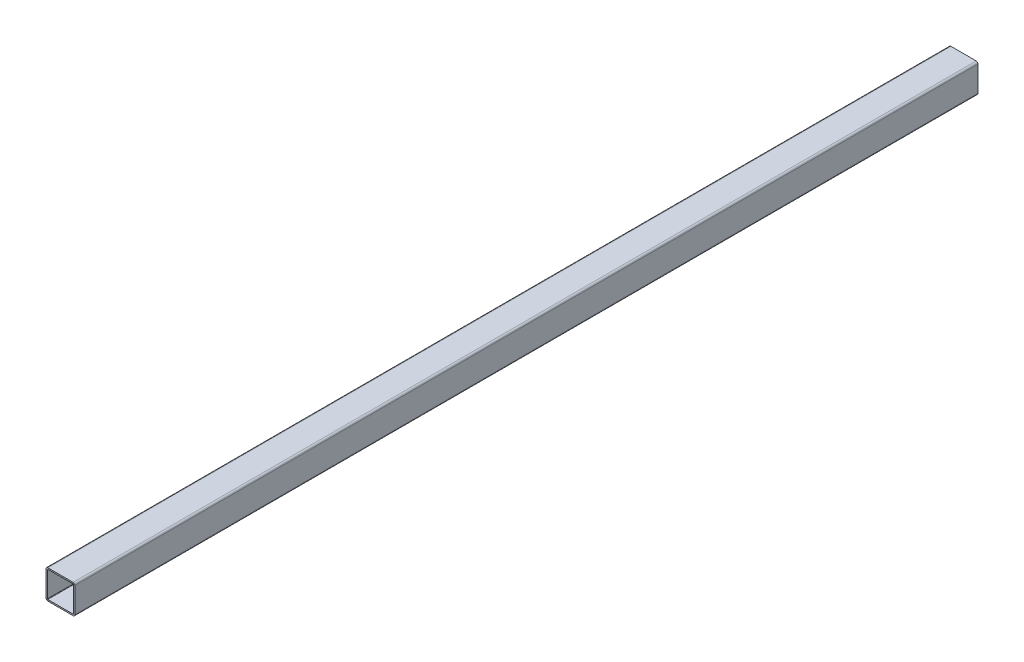
from build123d import *

# Parameters (mm, degrees)
BOSS_EXTRUDE1_DEPTH      = 500
BOSS_EXTRUDE1_DEPTH_BACK = 500


with BuildPart() as part:
    # Sketch1 → Boss-Extrude1 (new body, two sides)
    with BuildSketch(Plane.XY) as boss_extrude1_sk:
        with BuildLine():
            Line((-14, -16), (14, -16))
            ThreePointArc((14, -16), (15.414213562, -15.414213562), (16, -14))
            Line((16, -14), (16, 14))
            ThreePointArc((16, 14), (15.414213562, 15.414213562), (14, 16))
            Line((14, 16), (-14, 16))
            ThreePointArc((-14, 16), (-15.414213562, 15.414213562), (-16, 14))
            Line((-16, 14), (-16, -14))
            ThreePointArc((-16, -14), (-15.414213562, -15.414213562), (-14, -16))
        make_face()
        with BuildLine():
            Line((-14, 14.48), (14, 14.48))
            ThreePointArc((14, 14.48), (14.339411255, 14.339411255), (14.48, 14))
            Line((14.48, 14), (14.48, -14))
            ThreePointArc((14.48, -14), (14.339411255, -14.339411255), (14, -14.48))
            Line((14, -14.48), (-14, -14.48))
            ThreePointArc((-14, -14.48), (-14.339411255, -14.339411255), (-14.48, -14))
            Line((-14.48, -14), (-14.48, 14))
            ThreePointArc((-14.48, 14), (-14.339411255, 14.339411255), (-14, 14.48))
        make_face(mode=Mode.SUBTRACT)
    extrude(amount=BOSS_EXTRUDE1_DEPTH)
    extrude(boss_extrude1_sk.sketch, amount=-BOSS_EXTRUDE1_DEPTH_BACK)


solid = part.part
